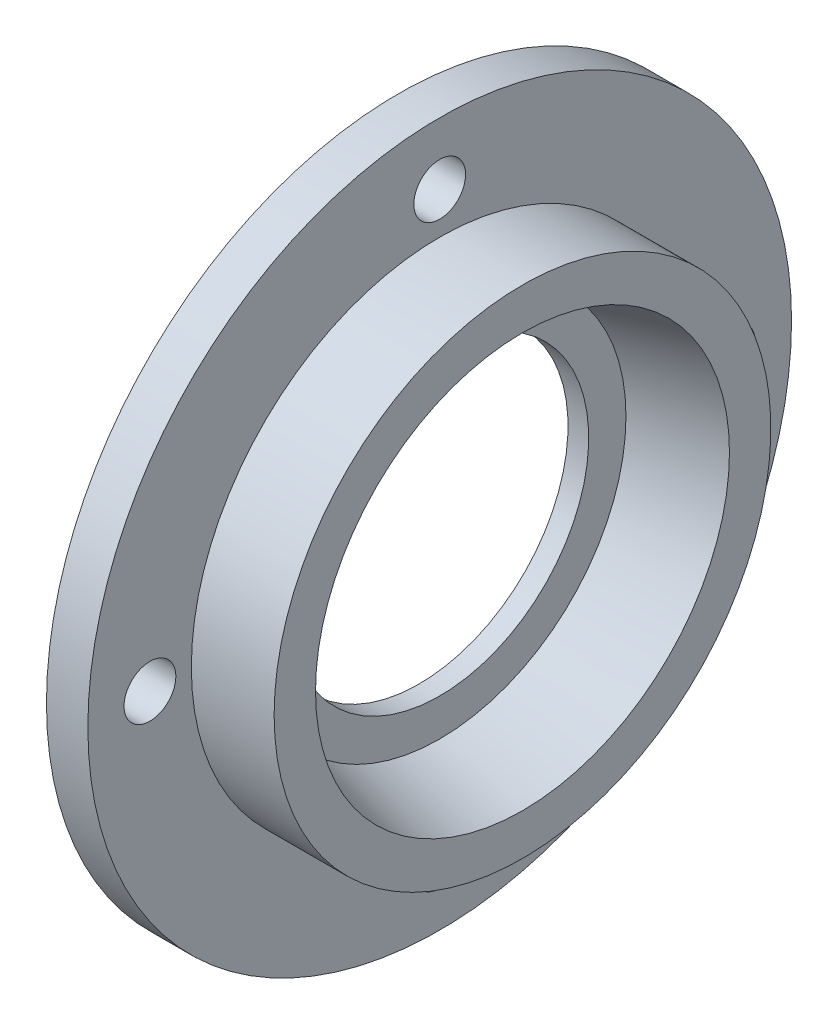
from build123d import *

# Parameters (mm, degrees)
CUT_EXTRUDE3_REACH = 8
SKETCH4_R          = 1.25
SKETCH2_R          = 12
CUT_EXTRUDE4_DEPTH = 1
CUT_EXTRUDE5_REACH = 7
SKETCH5_R          = 7.2


with BuildPart() as part:
    # Sketch1 → Revolve1 (revolve)
    with BuildSketch(Plane.XY):
        Polygon((0, 0), (0, 17), (2, 17), (2, 12), (6, 12), (6, 10), (2, 9), (2, 0), align=None)
    revolve(axis=Axis((0, 0, 0), (1, 0, 0)))

    # Sketch4 → Cut-Extrude3 (cut, up to next)
    with BuildSketch(Plane.ZY, mode=Mode.PRIVATE) as cut_extrude3_sk1:
        with Locations((0, 14)):
            Circle(SKETCH4_R)
    cut_extrude3_tool1 = extrude(cut_extrude3_sk1.sketch, amount=-CUT_EXTRUDE3_REACH, mode=Mode.PRIVATE) & part.part
    add(cut_extrude3_tool1.solids().sort_by_distance((0, 14, 0))[0], mode=Mode.SUBTRACT)
    # Sketch4 → Cut-Extrude3 (cut, up to next)
    with BuildSketch(Plane.ZY, mode=Mode.PRIVATE) as cut_extrude3_sk2:
        with Locations((14, 0)):
            Circle(SKETCH4_R)
    cut_extrude3_tool2 = extrude(cut_extrude3_sk2.sketch, amount=-CUT_EXTRUDE3_REACH, mode=Mode.PRIVATE) & part.part
    add(cut_extrude3_tool2.solids().sort_by_distance((0, 0, 14))[0], mode=Mode.SUBTRACT)
    # Sketch4 → Cut-Extrude3 (cut, up to next)
    with BuildSketch(Plane.ZY, mode=Mode.PRIVATE) as cut_extrude3_sk3:
        with Locations((0, -14)):
            Circle(SKETCH4_R)
    cut_extrude3_tool3 = extrude(cut_extrude3_sk3.sketch, amount=-CUT_EXTRUDE3_REACH, mode=Mode.PRIVATE) & part.part
    add(cut_extrude3_tool3.solids().sort_by_distance((0, -14, 0))[0], mode=Mode.SUBTRACT)
    # Sketch4 → Cut-Extrude3 (cut, up to next)
    with BuildSketch(Plane.ZY, mode=Mode.PRIVATE) as cut_extrude3_sk4:
        with Locations((-14, 0)):
            Circle(SKETCH4_R)
    cut_extrude3_tool4 = extrude(cut_extrude3_sk4.sketch, amount=-CUT_EXTRUDE3_REACH, mode=Mode.PRIVATE) & part.part
    add(cut_extrude3_tool4.solids().sort_by_distance((0, 0, -14))[0], mode=Mode.SUBTRACT)

    # Sketch2 → Cut-Extrude4 (cut)
    with BuildSketch(Plane.ZY):
        Circle(SKETCH2_R)
    extrude(amount=-CUT_EXTRUDE4_DEPTH, mode=Mode.SUBTRACT)

    # Sketch5 → Cut-Extrude5 (cut, up to next)
    with BuildSketch(Plane.ZY.offset(-1), mode=Mode.PRIVATE) as cut_extrude5_sk1:
        Circle(SKETCH5_R)
    cut_extrude5_tool1 = extrude(cut_extrude5_sk1.sketch, amount=-CUT_EXTRUDE5_REACH, mode=Mode.PRIVATE) & part.part
    add(cut_extrude5_tool1.solids().sort_by_distance((1, 0, 0))[0], mode=Mode.SUBTRACT)


solid = part.part
